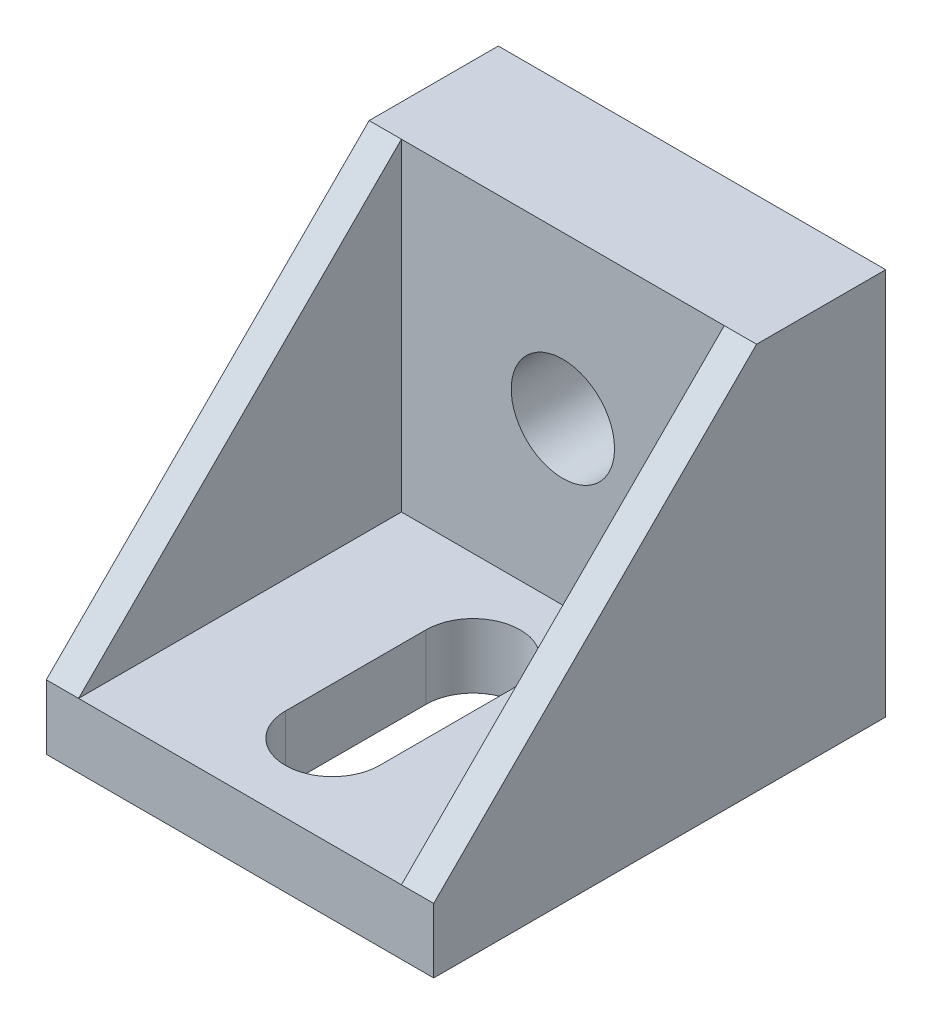
from build123d import *

# Parameters (mm, degrees)
SKETCH1_W               = 30
SKETCH1_H               = 25
SKETCH1_R               = 4
BOSS_EXTRUDE1_DEPTH     = 10
SKETCH2_W               = 30
SKETCH2_H               = 35
BOSS_EXTRUDE3_DEPTH     = 5
BOSS_EXTRUDE4_DEPTH     = 2.5
CUT_EXTRUDE1_DEPTH      = 26
CUT_EXTRUDE1_DEPTH_BACK = 6


with BuildPart() as part:
    # Sketch1 → Boss-Extrude1 (new body)
    with BuildSketch(Plane.XY):
        Rectangle(SKETCH1_W, SKETCH1_H)
        Circle(SKETCH1_R, mode=Mode.SUBTRACT)
    extrude(amount=BOSS_EXTRUDE1_DEPTH)

    # Sketch2 → Boss-Extrude3 (add)
    with BuildSketch(Plane.XZ.offset(12.5)):
        with Locations((0, 17.5)):
            Rectangle(SKETCH2_W, SKETCH2_H)
    extrude(amount=BOSS_EXTRUDE3_DEPTH)

    # Sketch7 → Boss-Extrude4 (add)
    with BuildSketch(Plane(origin=(15, 0, 0), x_dir=(0, 0, -1), z_dir=(1, 0, 0))):
        Polygon((-35, -12.5), (-10, 12.5), (-10, -12.5), align=None)
    boss_extrude4 = extrude(amount=-BOSS_EXTRUDE4_DEPTH)

    # Mirror1: Boss-Extrude4 across plane
    add(boss_extrude4.mirror(Plane(origin=(0, 0, 0), x_dir=(0, 0, 1), z_dir=(1, 0, 0))))

    # Sketch8 → Cut-Extrude1 (cut, two sides)
    with BuildSketch(Plane(origin=(0, -12.5, 0), x_dir=(1, 0, 0), z_dir=(0, 1, 0))) as cut_extrude1_sk:
        with BuildLine():
            Line((3.647363535, -16.948096307), (3.647363535, -27.842195287))
            ThreePointArc((3.647363535, -27.842195287), (0, -31.489558822), (-3.647363535, -27.842195287))
            Line((-3.647363535, -27.842195287), (-3.647363535, -16.948096307))
            ThreePointArc((-3.647363535, -16.948096307), (0, -13.300732772), (3.647363535, -16.948096307))
        make_face()
    extrude(amount=CUT_EXTRUDE1_DEPTH, mode=Mode.SUBTRACT)
    extrude(cut_extrude1_sk.sketch, amount=-CUT_EXTRUDE1_DEPTH_BACK, mode=Mode.SUBTRACT)


solid = part.part
